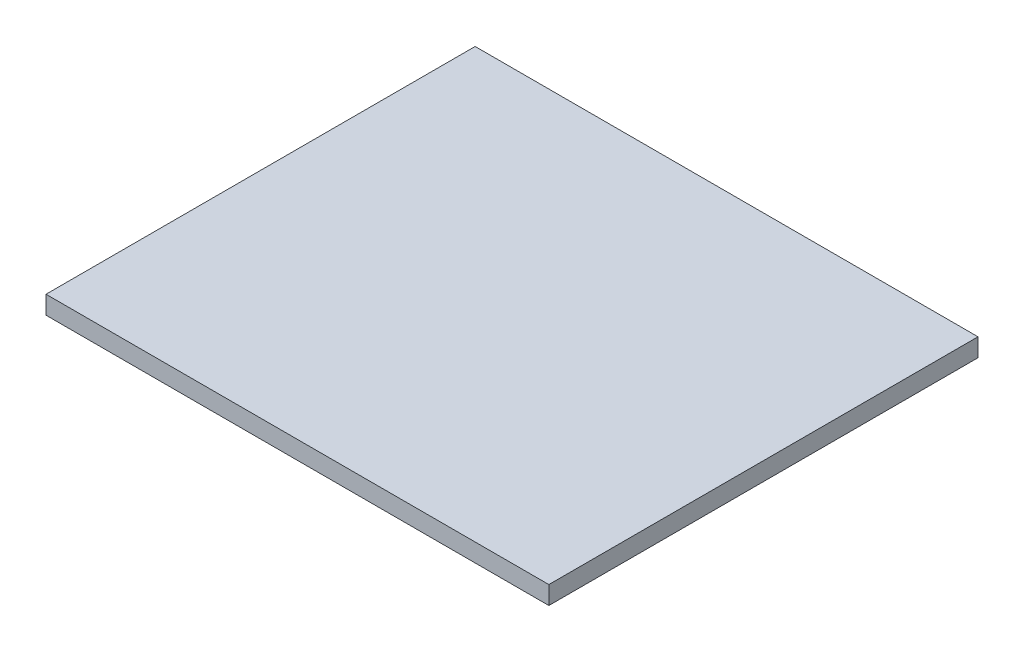
from build123d import *

# Parameters (mm, degrees)
SKETCH_1_W      = 498
SKETCH_1_H      = 425
EXTRUDE_1_DEPTH = 18


with BuildPart() as part:
    # Эскиз1 → Бобышка-Вытянуть1 (new body)
    with BuildSketch(Plane(origin=(0, 0, 0), x_dir=(1, 0, 0), z_dir=(0, 1, 0))):
        Rectangle(SKETCH_1_W, SKETCH_1_H)
    extrude(amount=EXTRUDE_1_DEPTH)


solid = part.part
